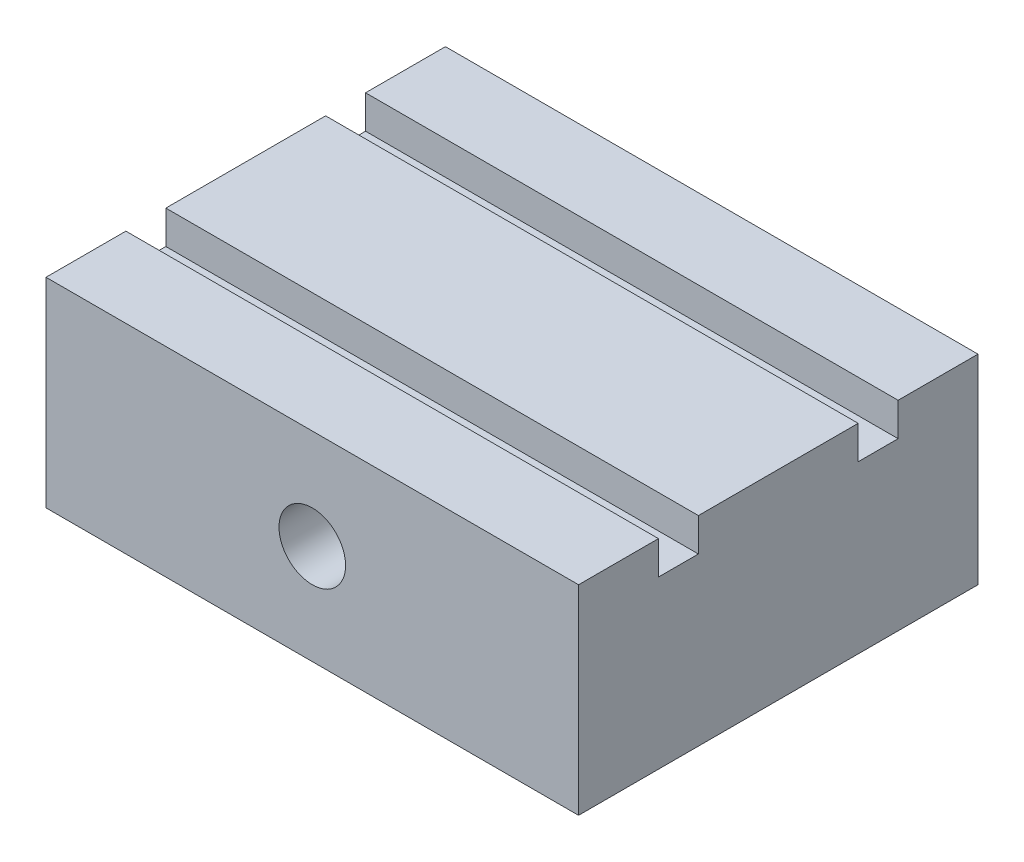
from build123d import *

# Parameters (mm, degrees)
SKETCH_1_W          = 80
SKETCH_1_H          = 60
EXTRUDE_1_DEPTH     = 30
SKETCH_2_R          = 5
CUT_EXTRUDE_1_DEPTH = 61
SKETCH_3_W          = 80
SKETCH_3_H          = 6
CUT_EXTRUDE_2_DEPTH = 5


with BuildPart() as part:
    # 草图1 → 凸台-拉伸1 (new body)
    with BuildSketch(Plane(origin=(0, 0, 0), x_dir=(1, 0, 0), z_dir=(0, 1, 0))):
        Rectangle(SKETCH_1_W, SKETCH_1_H)
    extrude(amount=EXTRUDE_1_DEPTH)

    # 草图2 → 切除-拉伸1 (cut, through all)
    with BuildSketch(Plane.XY.offset(30)):
        with Locations((0, 15)):
            Circle(SKETCH_2_R)
    extrude(amount=-CUT_EXTRUDE_1_DEPTH, mode=Mode.SUBTRACT)

    # 草图3 → 切除-拉伸2 (cut)
    with BuildSketch(Plane(origin=(0, 30, 0), x_dir=(1, 0, 0), z_dir=(0, 1, 0))):
        with Locations((0, 15)):
            Rectangle(SKETCH_3_W, SKETCH_3_H)
        with Locations((0, -15)):
            Rectangle(SKETCH_3_W, SKETCH_3_H)
    extrude(amount=-CUT_EXTRUDE_2_DEPTH, mode=Mode.SUBTRACT)


solid = part.part
